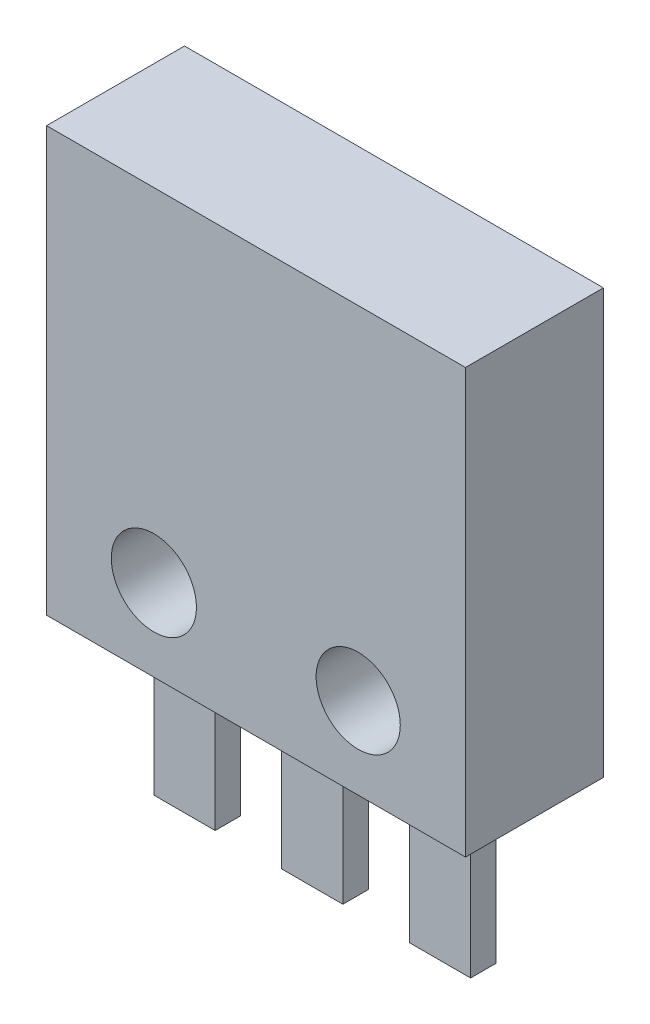
from build123d import *

# Parameters (mm, degrees)
SKETCH2_W           = 8.2
SKETCH2_H           = 8.3
SKETCH2_R           = 0.833443519
SKETCH2_R_2         = 0.823803164
BOSS_EXTRUDE1_DEPTH = 1.35
SKETCH3_W           = 1.2
SKETCH3_H           = 3.1
BOSS_EXTRUDE2_DEPTH = 0.25


with BuildPart() as part:
    # Sketch2 → Boss-Extrude1 (new body, symmetric)
    with BuildSketch(Plane.XY):
        Rectangle(SKETCH2_W, SKETCH2_H)
        with Locations((-2, -2.55)):
            Circle(SKETCH2_R, mode=Mode.SUBTRACT)
        with Locations((2, -2.55)):
            Circle(SKETCH2_R_2, mode=Mode.SUBTRACT)
    extrude(amount=BOSS_EXTRUDE1_DEPTH, both=True)

    # Sketch3 → Boss-Extrude2 (add, symmetric)
    with BuildSketch(Plane.XY):
        with Locations((0, -5.7)):
            Rectangle(SKETCH3_W, SKETCH3_H)
        with Locations((2.5, -5.7)):
            Rectangle(SKETCH3_W, SKETCH3_H)
        with Locations((-2.5, -5.7)):
            Rectangle(SKETCH3_W, SKETCH3_H)
    extrude(amount=BOSS_EXTRUDE2_DEPTH, both=True)


solid = part.part
